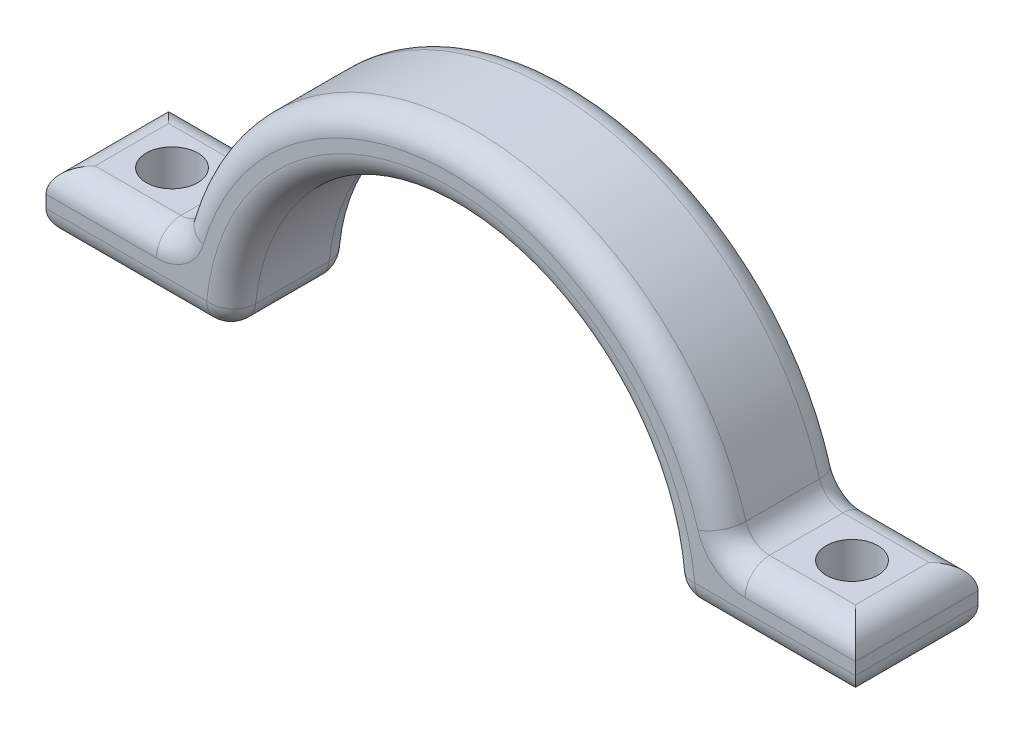
from build123d import *

# Parameters (mm, degrees)
BOSS_EXTRUDE1_DEPTH = 10
BOSS_EXTRUDE2_START = -0.550056
SKETCH2_W           = 10
SKETCH2_H           = 5
BOSS_EXTRUDE2_DEPTH = 10.550056
SKETCH3_R           = 2.1
CUT_EXTRUDE1_DEPTH  = 10
FILLET1_R           = 2


with BuildPart() as part:
    # Sketch1 → Boss-Extrude1 (new body)
    with BuildSketch(Plane.XY):
        with BuildLine():
            Line((-23, 0), (-18, 0))
            ThreePointArc((-18, 0), (0, 18), (18, 0))
            Line((18, 0), (23, 0))
            ThreePointArc((23, 0), (0, 23), (-23, 0))
        make_face()
    extrude(amount=BOSS_EXTRUDE1_DEPTH)

    # Sketch2 → Boss-Extrude2 (add)
    with BuildSketch(Plane.ZY.offset(23).offset(BOSS_EXTRUDE2_START)):
        with Locations((5, 2.5)):
            Rectangle(SKETCH2_W, SKETCH2_H)
    boss_extrude2 = extrude(amount=BOSS_EXTRUDE2_DEPTH)

    # Sketch3 → Cut-Extrude1 (cut)
    with BuildSketch(Plane(origin=(0, 5, 0), x_dir=(1, 0, 0), z_dir=(0, 1, 0))):
        with Locations((-27.72497216, -5)):
            Circle(SKETCH3_R)
    cut_extrude1 = extrude(amount=-CUT_EXTRUDE1_DEPTH, mode=Mode.SUBTRACT)

    # Mirror1: Boss-Extrude2, Cut-Extrude1 across plane
    add(boss_extrude2.mirror(Plane(origin=(0, 0, 0), x_dir=(0, 0, 1), z_dir=(1, 0, 0))))
    add(cut_extrude1.mirror(Plane(origin=(0, 0, 0), x_dir=(0, 0, 1), z_dir=(1, 0, 0))), mode=Mode.SUBTRACT)

    # Fillet1
    fillet1_edges = [part.edges().sort_by_distance(p)[0] for p in [
        (0, 18, 10),
        (-22.449944, 5, 5),
        (-27.724972, 5, 0),
        (-27.724972, 5, 10),
        (-33, 5, 5),
        (-33, 0, 5),
        (25.5, 0, 10),
        (0, 23, 0),
        (0, 23, 10),
        (27.724972, 5, 0),
        (27.724972, 5, 10),
        (33, 5, 5),
        (22.449944, 5, 5),
        (33, 0, 5),
        (25.5, 0, 0),
        (0, 18, 0),
        (-25.5, 0, 0),
        (18, 0, 5),
        (-18, 0, 5),
        (-25.5, 0, 10),
    ]]
    fillet(fillet1_edges, radius=FILLET1_R)


solid = part.part
